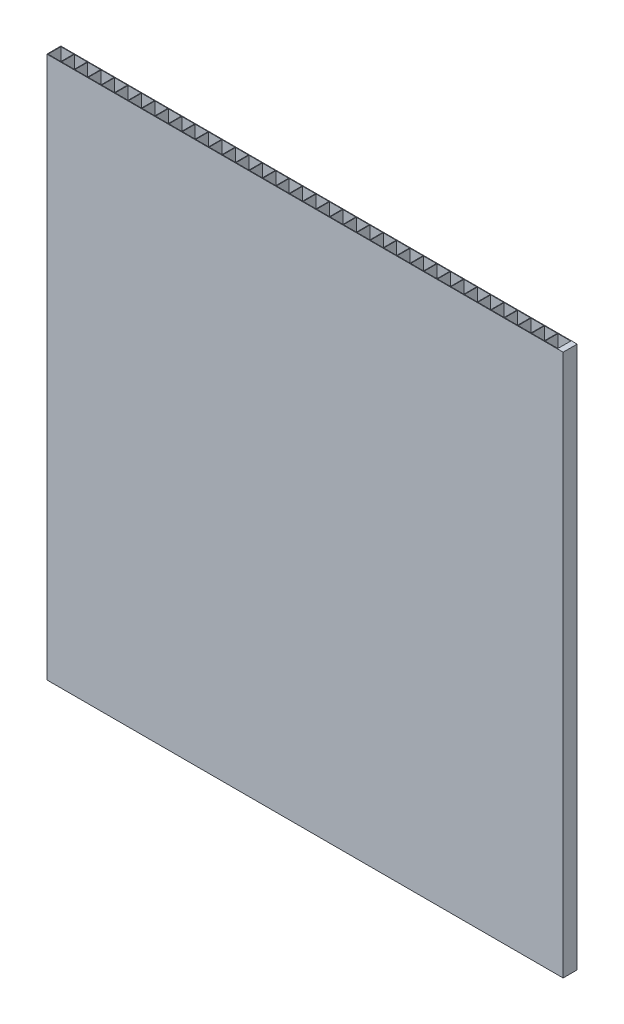
from build123d import *

# Parameters (mm, degrees)
SKETCH1_W           = 221
SKETCH1_H           = 6
SKETCH1_W_2         = 5.5
SKETCH1_H_2         = 5.5
BOSS_EXTRUDE1_DEPTH = 232


with BuildPart() as part:
    # Sketch1 → Boss-Extrude1 (new body)
    with BuildSketch(Plane(origin=(0, 0, 0), x_dir=(1, 0, 0), z_dir=(0, 1, 0))):
        with Locations((110.5, 3)):
            Rectangle(SKETCH1_W, SKETCH1_H)
        with Locations((8.75, 3)):
            Rectangle(SKETCH1_W_2, SKETCH1_H_2, mode=Mode.SUBTRACT)
        with Locations((3, 3)):
            Rectangle(SKETCH1_W_2, SKETCH1_H_2, mode=Mode.SUBTRACT)
        with Locations((14.5, 3)):
            Rectangle(SKETCH1_W_2, SKETCH1_H_2, mode=Mode.SUBTRACT)
        with Locations((20.25, 3)):
            Rectangle(SKETCH1_W_2, SKETCH1_H_2, mode=Mode.SUBTRACT)
        with Locations((26, 3)):
            Rectangle(SKETCH1_W_2, SKETCH1_H_2, mode=Mode.SUBTRACT)
        with Locations((31.75, 3)):
            Rectangle(SKETCH1_W_2, SKETCH1_H_2, mode=Mode.SUBTRACT)
        with Locations((37.5, 3)):
            Rectangle(SKETCH1_W_2, SKETCH1_H_2, mode=Mode.SUBTRACT)
        with Locations((43.25, 3)):
            Rectangle(SKETCH1_W_2, SKETCH1_H_2, mode=Mode.SUBTRACT)
        with Locations((49, 3)):
            Rectangle(SKETCH1_W_2, SKETCH1_H_2, mode=Mode.SUBTRACT)
        with Locations((54.75, 3)):
            Rectangle(SKETCH1_W_2, SKETCH1_H_2, mode=Mode.SUBTRACT)
        with Locations((60.5, 3)):
            Rectangle(SKETCH1_W_2, SKETCH1_H_2, mode=Mode.SUBTRACT)
        with Locations((66.25, 3)):
            Rectangle(SKETCH1_W_2, SKETCH1_H_2, mode=Mode.SUBTRACT)
        with Locations((72, 3)):
            Rectangle(SKETCH1_W_2, SKETCH1_H_2, mode=Mode.SUBTRACT)
        with Locations((77.75, 3)):
            Rectangle(SKETCH1_W_2, SKETCH1_H_2, mode=Mode.SUBTRACT)
        with Locations((83.5, 3)):
            Rectangle(SKETCH1_W_2, SKETCH1_H_2, mode=Mode.SUBTRACT)
        with Locations((89.25, 3)):
            Rectangle(SKETCH1_W_2, SKETCH1_H_2, mode=Mode.SUBTRACT)
        with Locations((95, 3)):
            Rectangle(SKETCH1_W_2, SKETCH1_H_2, mode=Mode.SUBTRACT)
        with Locations((100.75, 3)):
            Rectangle(SKETCH1_W_2, SKETCH1_H_2, mode=Mode.SUBTRACT)
        with Locations((106.5, 3)):
            Rectangle(SKETCH1_W_2, SKETCH1_H_2, mode=Mode.SUBTRACT)
        with Locations((112.25, 3)):
            Rectangle(SKETCH1_W_2, SKETCH1_H_2, mode=Mode.SUBTRACT)
        with Locations((118, 3)):
            Rectangle(SKETCH1_W_2, SKETCH1_H_2, mode=Mode.SUBTRACT)
        with Locations((123.75, 3)):
            Rectangle(SKETCH1_W_2, SKETCH1_H_2, mode=Mode.SUBTRACT)
        with Locations((129.5, 3)):
            Rectangle(SKETCH1_W_2, SKETCH1_H_2, mode=Mode.SUBTRACT)
        with Locations((135.25, 3)):
            Rectangle(SKETCH1_W_2, SKETCH1_H_2, mode=Mode.SUBTRACT)
        with Locations((141, 3)):
            Rectangle(SKETCH1_W_2, SKETCH1_H_2, mode=Mode.SUBTRACT)
        with Locations((146.75, 3)):
            Rectangle(SKETCH1_W_2, SKETCH1_H_2, mode=Mode.SUBTRACT)
        with Locations((152.5, 3)):
            Rectangle(SKETCH1_W_2, SKETCH1_H_2, mode=Mode.SUBTRACT)
        with Locations((158.25, 3)):
            Rectangle(SKETCH1_W_2, SKETCH1_H_2, mode=Mode.SUBTRACT)
        with Locations((164, 3)):
            Rectangle(SKETCH1_W_2, SKETCH1_H_2, mode=Mode.SUBTRACT)
        with Locations((169.75, 3)):
            Rectangle(SKETCH1_W_2, SKETCH1_H_2, mode=Mode.SUBTRACT)
        with Locations((175.5, 3)):
            Rectangle(SKETCH1_W_2, SKETCH1_H_2, mode=Mode.SUBTRACT)
        with Locations((181.25, 3)):
            Rectangle(SKETCH1_W_2, SKETCH1_H_2, mode=Mode.SUBTRACT)
        with Locations((187, 3)):
            Rectangle(SKETCH1_W_2, SKETCH1_H_2, mode=Mode.SUBTRACT)
        with Locations((192.75, 3)):
            Rectangle(SKETCH1_W_2, SKETCH1_H_2, mode=Mode.SUBTRACT)
        with Locations((198.5, 3)):
            Rectangle(SKETCH1_W_2, SKETCH1_H_2, mode=Mode.SUBTRACT)
        with Locations((204.25, 3)):
            Rectangle(SKETCH1_W_2, SKETCH1_H_2, mode=Mode.SUBTRACT)
        with Locations((210, 3)):
            Rectangle(SKETCH1_W_2, SKETCH1_H_2, mode=Mode.SUBTRACT)
        with Locations((215.75, 3)):
            Rectangle(SKETCH1_W_2, SKETCH1_H_2, mode=Mode.SUBTRACT)
    extrude(amount=BOSS_EXTRUDE1_DEPTH)


solid = part.part
